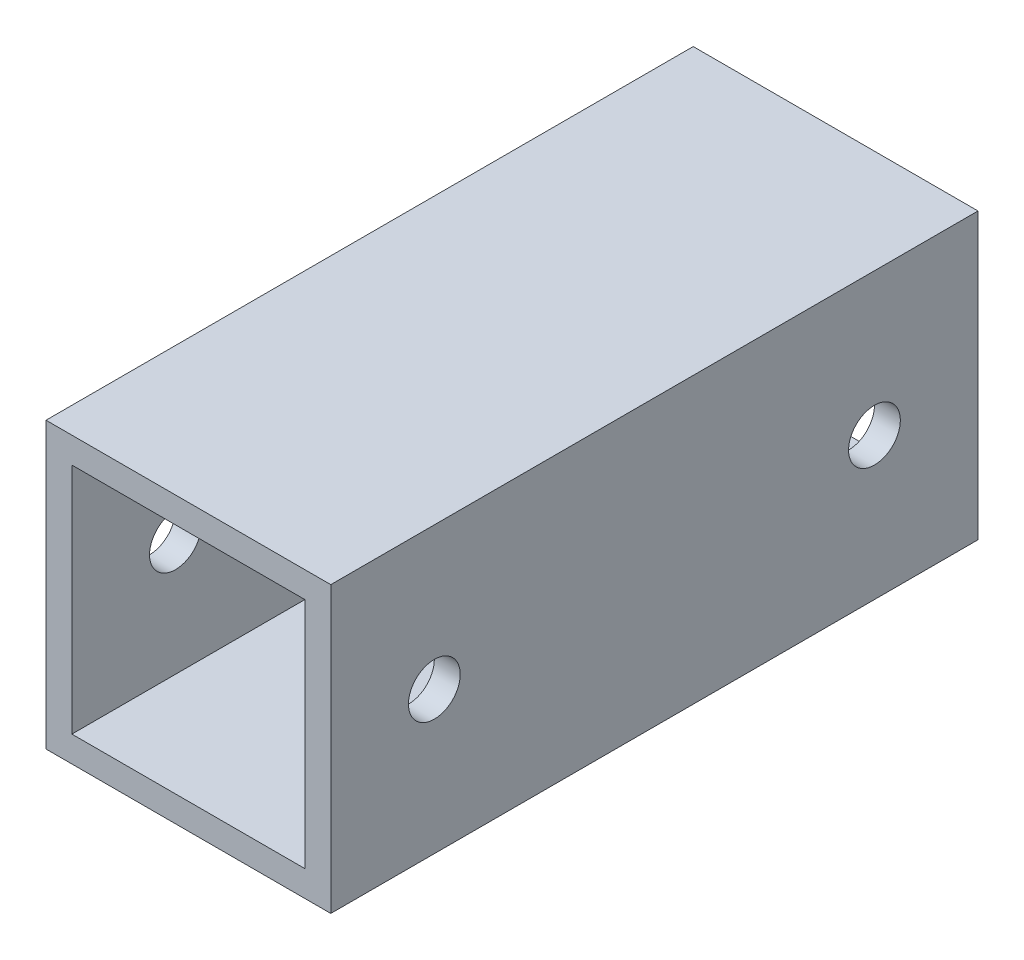
from build123d import *

# Parameters (mm, degrees)
SKETCH1_W           = 44
SKETCH1_H           = 44
SKETCH1_W_2         = 36
SKETCH1_H_2         = 36
EXTRUDE_THIN1_DEPTH = 50
SKETCH2_R           = 4
CUT_EXTRUDE1_DEPTH  = 45


with BuildPart() as part:
    # Sketch1 → Extrude-Thin1 (new body, symmetric)
    with BuildSketch(Plane.XY):
        Rectangle(SKETCH1_W, SKETCH1_H)
        Rectangle(SKETCH1_W_2, SKETCH1_H_2, mode=Mode.SUBTRACT)
    extrude(amount=EXTRUDE_THIN1_DEPTH, both=True)

    # Sketch2 → Cut-Extrude1 (cut, through all)
    with BuildSketch(Plane.ZY.offset(22)):
        with Locations((34, 0)):
            Circle(SKETCH2_R)
        with Locations((-34, 0)):
            Circle(SKETCH2_R)
    extrude(amount=-CUT_EXTRUDE1_DEPTH, mode=Mode.SUBTRACT)


solid = part.part
